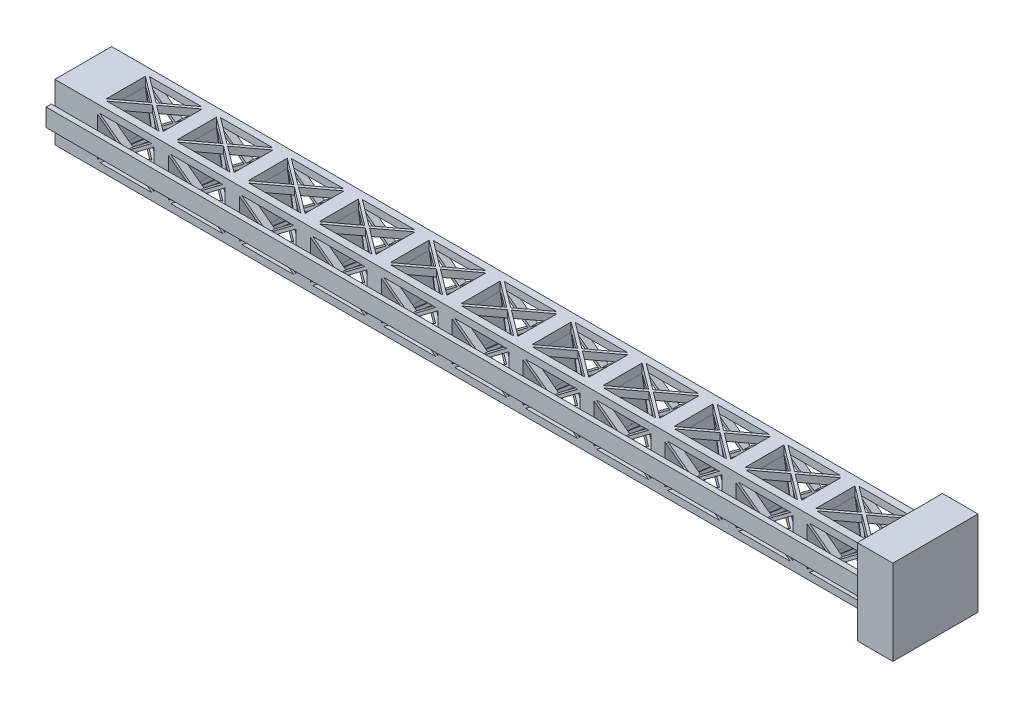
from build123d import *

# Parameters (mm, degrees)
SKETCH2_W           = 3048
SKETCH2_H           = 203.2
BOSS_EXTRUDE1_DEPTH = 203.2
CUT_EXTRUDE6_DEPTH  = 203.2
CUT_EXTRUDE7_DEPTH  = 203.2
LPATTERN4_COUNT     = 6
LPATTERN4_PITCH     = 254
LPATTERN4_COL_COUNT = 6
LPATTERN4_COL_PITCH = 254
LPATTERN5_COUNT     = 6
LPATTERN5_PITCH     = 254
LPATTERN5_COL_COUNT = 6
LPATTERN5_COL_PITCH = 254
BOSS_EXTRUDE2_START = -124.46
SKETCH10_W          = 304.8
SKETCH10_H          = 304.8
BOSS_EXTRUDE2_DEPTH = 127
BOSS_EXTRUDE3_DEPTH = 2923.54


with BuildPart() as part:
    # Sketch2 → Boss-Extrude1 (new body)
    with BuildSketch(Plane.XY):
        Rectangle(SKETCH2_W, SKETCH2_H)
    extrude(amount=-BOSS_EXTRUDE1_DEPTH)

    # Sketch6 → Cut-Extrude6 (cut)
    with BuildSketch(Plane(origin=(0, 0, -203.2), x_dir=(-1, 0, 0), z_dir=(0, 0, -1))):
        Polygon((-93.133333333, 76.2), (0, 6.35), (93.133333333, 76.2), align=None)
        Polygon((-93.133333333, -76.2), (93.133333333, -76.2), (0, -6.35), align=None)
        Polygon((-101.6, -69.85), (-101.6, 69.85), (-8.466666667, 0), align=None)
        Polygon((101.6, -69.85), (101.6, 69.85), (8.466666667, 0), align=None)
    cut_extrude6 = extrude(amount=-CUT_EXTRUDE6_DEPTH, mode=Mode.SUBTRACT)

    # Sketch8 → Cut-Extrude7 (cut)
    with BuildSketch(Plane(origin=(0, 101.6, 0), x_dir=(1, 0, 0), z_dir=(0, 1, 0))):
        Polygon((-93.118630173, 177.951685502), (0.014703161, 108.101685502), (93.148036494, 177.951685502), align=None)
        Polygon((-93.118630173, 25.551685502), (93.148036494, 25.551685502), (0.014703161, 95.401685502), align=None)
        Polygon((-101.585296839, 31.901685502), (-101.585296839, 171.601685502), (-8.451963506, 101.751685502), align=None)
        Polygon((101.614703161, 31.901685502), (101.614703161, 171.601685502), (8.481369827, 101.751685502), align=None)
    cut_extrude7 = extrude(amount=-CUT_EXTRUDE7_DEPTH, mode=Mode.SUBTRACT)

    # LPattern4: Cut-Extrude6 ×6
    with Locations(*[(-i * LPATTERN4_PITCH, 0, 0) for i in range(1, LPATTERN4_COUNT)]):
        add(cut_extrude6, mode=Mode.SUBTRACT)

    # LPattern4 col: Cut-Extrude6 ×6
    with Locations(*[(i * LPATTERN4_COL_PITCH, 0, 0) for i in range(1, LPATTERN4_COL_COUNT)]):
        add(cut_extrude6, mode=Mode.SUBTRACT)

    # LPattern5: Cut-Extrude7 ×6
    with Locations(*[(i * LPATTERN5_PITCH, 0, 0) for i in range(1, LPATTERN5_COUNT)]):
        add(cut_extrude7, mode=Mode.SUBTRACT)

    # LPattern5 col: Cut-Extrude7 ×6
    with Locations(*[(-i * LPATTERN5_COL_PITCH, 0, 0) for i in range(1, LPATTERN5_COL_COUNT)]):
        add(cut_extrude7, mode=Mode.SUBTRACT)

    # Sketch10 → Boss-Extrude2 (add)
    with BuildSketch(Plane(origin=(1524, 0, 0), x_dir=(0, 0, -1), z_dir=(1, 0, 0)).offset(BOSS_EXTRUDE2_START)):
        with Locations((101.6, 0)):
            Rectangle(SKETCH10_W, SKETCH10_H)
    extrude(amount=BOSS_EXTRUDE2_DEPTH)

    # Sketch11 → Boss-Extrude3 (add)
    with BuildSketch(Plane.ZY.offset(1524)):
        Polygon((12.817821032, 31.75), (12.817821032, 12.817821032), (0, 12.817821032), (0, -12.817821032), (12.817821032, -12.817821032), (12.817821032, -31.75), (31.75, -31.75), (31.75, 31.75), align=None)
    extrude(amount=-BOSS_EXTRUDE3_DEPTH)


solid = part.part
